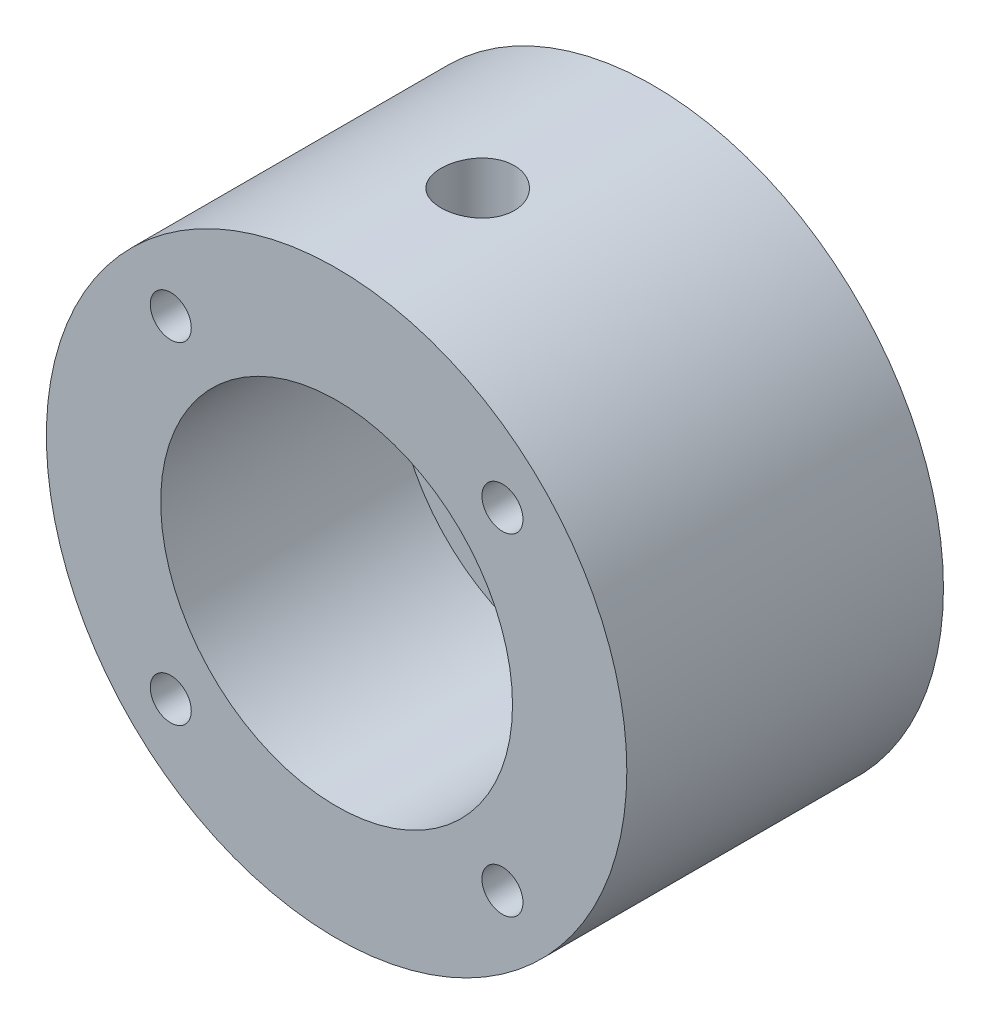
from build123d import *

# Parameters (mm, degrees)
SKETCH1_R                       = 12.573
BOSS_EXTRUDE1_DEPTH             = 13.716
SKETCH2_R                       = 7.62
CUT_EXTRUDE1_DEPTH              = 10.16
F_1_8_0_1250_DOWEL_HOLE1_REACH  = 31.128
F_1_8_0_1250_DOWEL_HOLE1_BORE_R = 1.5875
CUT_EXTRUDE3_DEPTH              = 10
CUT_EXTRUDE3_DEPTH_BACK         = 10.16
CIRPATTERN1_COUNT               = 4


with BuildPart() as part:
    # Sketch1 → Boss-Extrude1 (new body)
    with BuildSketch(Plane.XY):
        Circle(SKETCH1_R)
    extrude(amount=BOSS_EXTRUDE1_DEPTH)

    # Sketch2 → Cut-Extrude1 (cut)
    with BuildSketch(Plane.XY.offset(13.716)):
        Circle(SKETCH2_R)
    extrude(amount=-CUT_EXTRUDE1_DEPTH, mode=Mode.SUBTRACT)

    # 1_8 _0.1250_ Dowel Hole1 bore → 1_8 _0.1250_ Dowel Hole1 (cut, up to next)
    with BuildSketch(Plane(origin=(0, 12.573, 7.62), x_dir=(1, 0, 0), z_dir=(0, 1, 0)), mode=Mode.PRIVATE) as f_1_8_0_1250_dowel_hole1_sk1:
        with Locations((0, 0.014313547)):
            Circle(F_1_8_0_1250_DOWEL_HOLE1_BORE_R)
    f_1_8_0_1250_dowel_hole1_tool1 = extrude(f_1_8_0_1250_dowel_hole1_sk1.sketch, amount=-F_1_8_0_1250_DOWEL_HOLE1_REACH, mode=Mode.PRIVATE) & part.part
    add(f_1_8_0_1250_dowel_hole1_tool1.solids().sort_by_distance((0, 12.573, 7.605686))[0], mode=Mode.SUBTRACT)

    # Sketch5 → Cut-Extrude3 (cut, two sides)
    with BuildSketch(Plane(origin=(0, 0, 7.62), x_dir=(-1, 0, 0), z_dir=(0, 0, -1))) as cut_extrude3_sk:
        with BuildLine():
            Line((1.5, 1.99598875), (-1.5, 1.99598875))
            ThreePointArc((-1.5, 1.99598875), (-1.118033989, -2.240079228), (2.5, -0.00401125))
            ThreePointArc((2.5, -0.00401125), (2.236067977, 1.114022739), (1.5, 1.99598875))
        make_face()
    extrude(amount=CUT_EXTRUDE3_DEPTH, mode=Mode.SUBTRACT)
    extrude(cut_extrude3_sk.sketch, amount=-CUT_EXTRUDE3_DEPTH_BACK, mode=Mode.SUBTRACT)

    # Sketch15 → 2-56 Tapped Hole1 (revolve, cut)
    with BuildSketch(Plane(origin=(7.184204897, -7.188216147, 13.716), x_dir=(0, -1, 0), z_dir=(1, 0, 0))):
        Polygon((0, 0), (0, 8.24814509), (0.889, 7.71398), (0.889, 0), align=None)
    f_2_56_tapped_hole1 = revolve(axis=Axis((7.184204897, -7.188216147, 20.066), (0, 0, -1)), mode=Mode.SUBTRACT)

    # CirPattern1: 2-56 Tapped Hole1 ×4 about axis
    cirpattern1_axis = Axis((0, -0.00401125, 0), (0, 0, 1))
    for i in range(1, CIRPATTERN1_COUNT):
        add(f_2_56_tapped_hole1.rotate(cirpattern1_axis, i * 360 / CIRPATTERN1_COUNT), mode=Mode.SUBTRACT)


solid = part.part
